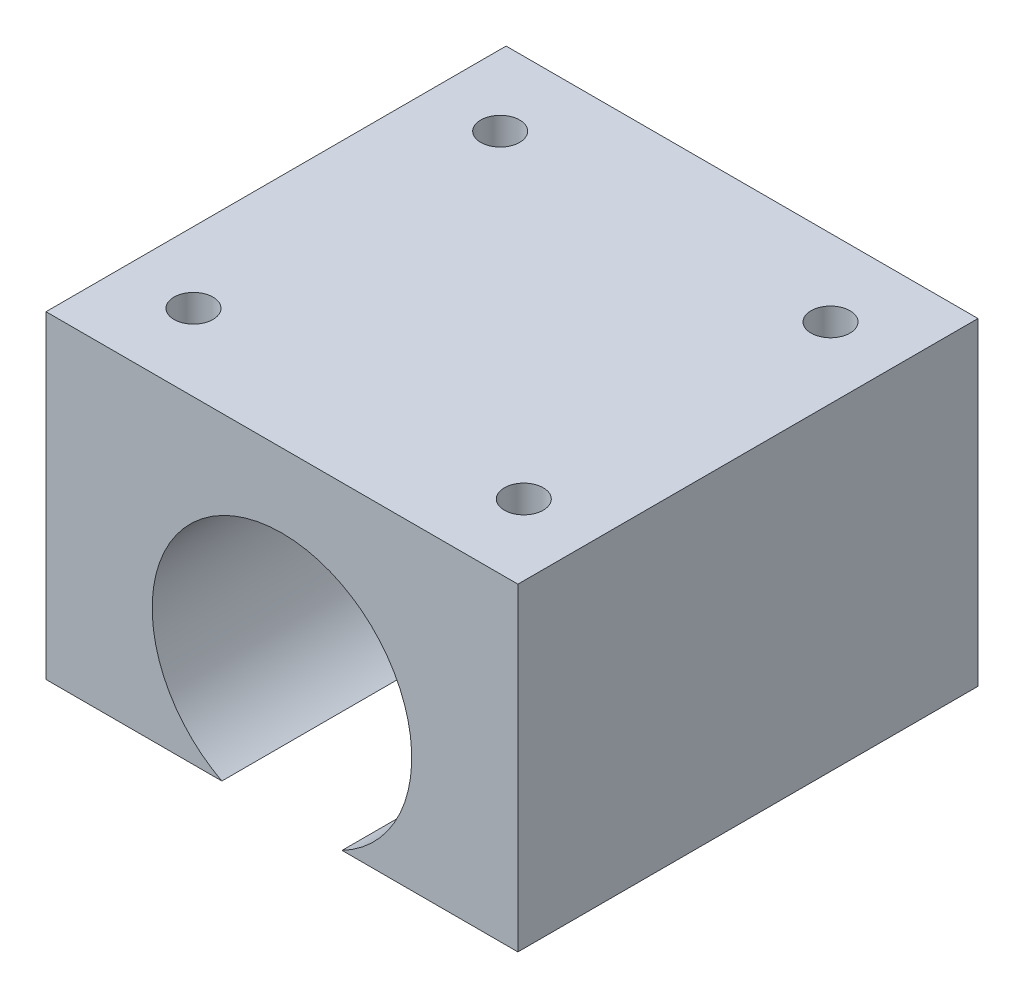
from build123d import *

# Parameters (mm, degrees)
BOSS_EXTRUDE1_DEPTH = 39
SKETCH2_R           = 1.65
CUT_EXTRUDE1_DEPTH  = 5


with BuildPart() as part:
    # Sketch1 → Boss-Extrude1 (new body)
    with BuildSketch(Plane.XY):
        with BuildLine():
            Line((-20, 17.25), (20, 17.25))
            Line((20, 17.25), (20, -9.75))
            Line((20, -9.75), (5.092887197, -9.75))
            ThreePointArc((5.092887197, -9.75), (0, 11), (-5.092887197, -9.75))
            Line((-5.092887197, -9.75), (-20, -9.75))
            Line((-20, -9.75), (-20, 17.25))
        make_face()
    extrude(amount=BOSS_EXTRUDE1_DEPTH)

    # Sketch2 → Cut-Extrude1 (cut)
    with BuildSketch(Plane(origin=(0, 17.25, 0), x_dir=(1, 0, 0), z_dir=(0, 1, 0))):
        with Locations((-14, -6.5)):
            Circle(SKETCH2_R)
        with Locations((14, -6.5)):
            Circle(SKETCH2_R)
        with Locations((-14, -32.5)):
            Circle(SKETCH2_R)
        with Locations((14, -32.5)):
            Circle(SKETCH2_R)
    extrude(amount=-CUT_EXTRUDE1_DEPTH, mode=Mode.SUBTRACT)


solid = part.part
